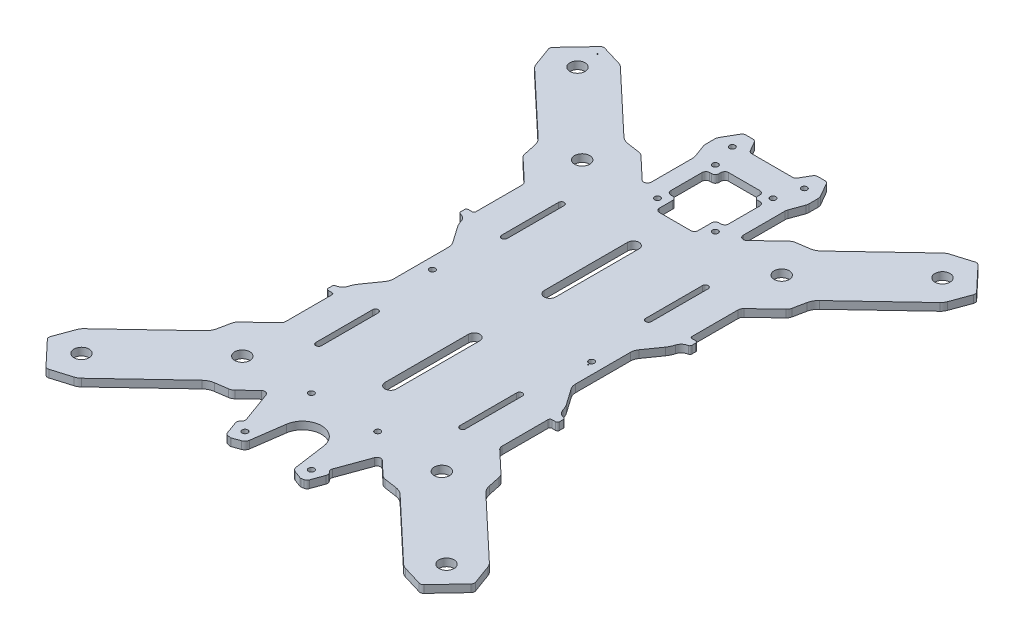
from build123d import *

# Parameters (mm, degrees)
SKETCH1_R          = 1.5
SKETCH1_R_2        = 4
SKETCH1_R_3        = 0.254
BOTTOM_PLATE_DEPTH = 4


with BuildPart() as part:
    # Sketch1 → Bottom Plate (new body)
    with BuildSketch(Plane(origin=(0, 0, 0), x_dir=(1, 0, 0), z_dir=(0, 1, 0))):
        with BuildLine():
            Line((-19.624898811, 134.691678828), (-13.018221488, 135.658834903))
            ThreePointArc((-13.018221488, 135.658834903), (-10.691575345, 136.373645712), (-8.6875614, 137.755009126))
            Line((-8.6875614, 137.755009126), (24.091416515, 168.675073503))
            ThreePointArc((24.091416515, 168.675073503), (25.204330576, 169.504226816), (26.477973526, 170.055504024))
            Line((26.477973526, 170.055504024), (36.784481999, 173.160034431))
            ThreePointArc((36.784481999, 173.160034431), (37.877411493, 173.17729229), (38.8161858, 172.617385592))
            Line((38.8161858, 172.617385592), (50.843443562, 159.867049173))
            ThreePointArc((50.843443562, 159.867049173), (51.347657912, 158.897227373), (51.266704223, 157.807166395))
            Line((51.266704223, 157.807166395), (47.566420562, 147.699238748))
            ThreePointArc((47.566420562, 147.699238748), (46.941808448, 146.459913287), (46.049166974, 145.397247256))
            Line((46.049166974, 145.397247256), (13.270189455, 114.477183253))
            ThreePointArc((13.270189455, 114.477183253), (11.774311214, 112.557136031), (10.925036406, 110.276135079))
            Line((10.925036406, 110.276135079), (9.574246944, 103.737103757))
            ThreePointArc((9.574246944, 103.737103757), (9.149610023, 102.596602447), (8.401670885, 101.636578073))
            Line((8.401670885, 101.636578073), (-2.965983987, 90.913586269))
            ThreePointArc((-2.965983987, 90.913586269), (-3.66204239, 89.919647341), (-3.907444774, 88.731291518))
            Line((-3.907444774, 88.731291518), (-3.907450446, 64.464527176))
            ThreePointArc((-3.907450446, 64.464527176), (-3.61455677, 63.757421483), (-2.907450695, 63.46452873))
            Line((-2.907450695, 63.46452873), (-0.907452036, 63.464528189))
            ThreePointArc((-0.907452036, 63.464528189), (-0.200344482, 63.171635289), (0.092549034, 62.464527992))
            Line((0.092549034, 62.464527992), (0.092549232, 60.375595433))
            ThreePointArc((0.092549232, 60.375595433), (-0.140485817, 59.733905951), (-0.730980692, 59.391288777))
            ThreePointArc((-0.730980692, 59.391288777), (-3.027155921, 58.268484481), (-4.387452049, 56.104528702))
            ThreePointArc((-4.387452049, 56.104528702), (-5.088187791, 54.273814882), (-6.077628341, 52.58161186))
            Line((-6.077628341, 52.58161186), (-11.822366716, 44.377279089))
            ThreePointArc((-11.822366716, 44.377279089), (-12.629756713, 42.740055323), (-12.907455493, 40.935820401))
            Line((-12.907455493, 40.935820401), (-12.907461824, 12.066910818))
            ThreePointArc((-12.907461824, 12.066910818), (-12.629763908, 10.262676198), (-11.822374932, 8.625452408))
            Line((-11.822374932, 8.625452408), (-6.077639868, 0.421117289))
            ThreePointArc((-6.077639868, 0.421117289), (-5.088199941, -1.271086382), (-4.387464951, -3.101800753))
            ThreePointArc((-4.387464951, -3.101800753), (-3.027169835, -5.265757168), (-0.730995131, -6.388562538))
            ThreePointArc((-0.730995131, -6.388562538), (-0.140500811, -6.731179641), (0.09253405, -7.372868644))
            Line((0.09253405, -7.372868644), (0.092534248, -9.461803425))
            ThreePointArc((0.092534248, -9.461803425), (-0.200359811, -10.16890933), (-0.907466329, -10.461801909))
            Line((-0.907466329, -10.461801909), (-2.907467998, -10.461801368))
            ThreePointArc((-2.907467998, -10.461801368), (-3.614573795, -10.754695022), (-3.9074666, -11.461801171))
            Line((-3.9074666, -11.461801171), (-3.907472272, -35.72856392))
            ThreePointArc((-3.907472272, -35.72856392), (-3.662070044, -36.916920912), (-2.966011152, -37.910860858))
            Line((-2.966011152, -37.910860858), (8.401640117, -48.633855273))
            ThreePointArc((8.401640117, -48.633855273), (9.149578237, -49.593879047), (9.574214838, -50.734379303))
            Line((9.574214838, -50.734379303), (10.925000641, -57.273415065))
            ThreePointArc((10.925000641, -57.273415065), (11.77427395, -59.554415248), (13.270150201, -61.474462442))
            Line((13.270150201, -61.474462442), (46.049117389, -92.394542749))
            ThreePointArc((46.049117389, -92.394542749), (46.941758557, -93.457210145), (47.566369902, -94.696536946))
            Line((47.566369902, -94.696536946), (51.266643639, -104.804462428))
            ThreePointArc((51.266643639, -104.804462428), (51.347623825, -105.8945101), (50.843444782, -106.864337511))
            Line((50.843444782, -106.864337511), (38.816186611, -119.614678522))
            ThreePointArc((38.816186611, -119.614678522), (37.877411266, -120.17458425), (36.784481384, -120.157326015))
            Line((36.784481384, -120.157326015), (26.477974293, -117.052786366))
            ThreePointArc((26.477974293, -117.052786366), (25.204332663, -116.501509573), (24.091419614, -115.672357204))
            Line((24.091419614, -115.672357204), (-8.687555748, -84.752285906))
            ThreePointArc((-8.687555748, -84.752285906), (-10.691567982, -83.370923772), (-13.018211962, -82.656113188))
            Line((-13.018211962, -82.656113188), (-19.624889184, -81.688950571))
            ThreePointArc((-19.624889184, -81.688950571), (-20.788211576, -81.331545356), (-21.790217948, -80.64086402))
            Line((-21.790217948, -80.64086402), (-29.02547143, -73.815918837))
            ThreePointArc((-29.02547143, -73.815918837), (-30.859146405, -73.324714244), (-32.277217146, -74.586744845))
            Line((-32.277217146, -74.586744845), (-38.206367832, -90.876949429))
            ThreePointArc((-38.206367832, -90.876949429), (-38.296598501, -91.908286737), (-37.85907169, -92.846566282))
            Line((-37.85907169, -92.846566282), (-37.302400952, -93.509977318))
            ThreePointArc((-37.302400952, -93.509977318), (-36.86487298, -94.448257233), (-36.955103118, -95.479595416))
            Line((-36.955103118, -95.479595416), (-39.324687874, -101.989981964))
            ThreePointArc((-39.324687874, -101.989981964), (-39.91849839, -102.838028097), (-40.856775935, -103.275553433))
            Line((-40.856775935, -103.275553433), (-42.176167362, -103.50820302))
            ThreePointArc((-42.176167362, -103.50820302), (-42.436971902, -103.519589968), (-42.691836905, -103.463087749))
            Line((-42.691836905, -103.463087749), (-46.669870003, -102.015201079))
            ThreePointArc((-46.669870003, -102.015201079), (-47.975246723, -101.084084501), (-48.614612679, -99.613643194))
            Line((-48.614612679, -99.613643194), (-51.004754984, -82.606900037))
            ThreePointArc((-51.004754984, -82.606900037), (-60.907435402, -73.998631063), (-70.810115964, -82.606899872))
            Line((-70.810115964, -82.606899872), (-73.200258099, -99.61364007))
            ThreePointArc((-73.200258099, -99.61364007), (-73.839623803, -101.084083654), (-75.145002094, -102.015201453))
            Line((-75.145002094, -102.015201453), (-79.123034259, -103.463086484))
            ThreePointArc((-79.123034259, -103.463086484), (-79.377898893, -103.519588734), (-79.63870308, -103.508201816))
            Line((-79.63870308, -103.508201816), (-80.958095517, -103.275555129))
            ThreePointArc((-80.958095517, -103.275555129), (-81.896373504, -102.838028656), (-82.490182969, -101.989980713))
            Line((-82.490182969, -101.989980713), (-84.85976779, -95.479601429))
            ThreePointArc((-84.85976779, -95.479601429), (-84.949998975, -94.448263707), (-84.512472115, -93.509983678))
            Line((-84.512472115, -93.509983678), (-83.955802324, -92.846566168))
            ThreePointArc((-83.955802324, -92.846566168), (-83.518277305, -91.90828859), (-83.608507711, -90.87695381))
            Line((-83.608507711, -90.87695381), (-89.537658586, -74.586749882))
            ThreePointArc((-89.537658586, -74.586749882), (-90.955728185, -73.324719412), (-92.789402057, -73.815924488))
            Line((-92.789402057, -73.815924488), (-100.024658295, -80.640868929))
            ThreePointArc((-100.024658295, -80.640868929), (-101.026663922, -81.331549011), (-102.189985044, -81.68895385))
            Line((-102.189985044, -81.68895385), (-108.796662331, -82.656110165))
            ThreePointArc((-108.796662331, -82.656110165), (-111.123308449, -83.370921057), (-113.127322343, -84.752284544))
            Line((-113.127322343, -84.752284544), (-145.906299139, -115.672350107))
            ThreePointArc((-145.906299139, -115.672350107), (-147.01921317, -116.50150346), (-148.2928561, -117.052780714))
            Line((-148.2928561, -117.052780714), (-158.599364461, -120.157311495))
            ThreePointArc((-158.599364461, -120.157311495), (-159.692293954, -120.174569393), (-160.631068282, -119.614662729))
            Line((-160.631068282, -119.614662729), (-172.658326505, -106.864326746))
            ThreePointArc((-172.658326505, -106.864326746), (-173.162535285, -105.894498992), (-173.081572191, -104.804435993))
            Line((-173.081572191, -104.804435993), (-169.381290893, -94.696507481))
            ThreePointArc((-169.381290893, -94.696507481), (-168.756679068, -93.457181874), (-167.864037843, -92.394515635))
            Line((-167.864037843, -92.394515635), (-135.08506755, -61.47444397))
            ThreePointArc((-135.08506755, -61.47444397), (-133.589189758, -59.554396399), (-132.739915484, -57.273395248))
            Line((-132.739915484, -57.273395248), (-131.38912755, -50.73436361))
            ThreePointArc((-131.38912755, -50.73436361), (-130.964490895, -49.593862201), (-130.216551982, -48.633837652))
            Line((-130.216551982, -48.633837652), (-118.848899616, -37.910843191))
            ThreePointArc((-118.848899616, -37.910843191), (-118.152841446, -36.9169041), (-117.907439339, -35.72854822))
            Line((-117.907439339, -35.72854822), (-117.907439339, -11.461783878))
            ThreePointArc((-117.907439339, -11.461783878), (-118.20033318, -10.754678254), (-118.907439324, -10.461785666))
            Line((-118.907439324, -10.461785666), (-120.907437983, -10.461785666))
            ThreePointArc((-120.907437983, -10.461785666), (-121.614545605, -10.168892932), (-121.907439287, -9.461785703))
            Line((-121.907439287, -9.461785703), (-121.907439973, -7.372853144))
            ThreePointArc((-121.907439973, -7.372853144), (-121.674405073, -6.731163608), (-121.083910279, -6.388546296))
            ThreePointArc((-121.083910279, -6.388546296), (-118.787735312, -5.265741463), (-117.42743969, -3.101785366))
            ThreePointArc((-117.42743969, -3.101785366), (-116.726704376, -1.271071382), (-115.737264222, 0.421131871))
            Line((-115.737264222, 0.421131871), (-109.992527765, 8.625465984))
            ThreePointArc((-109.992527765, 8.625465984), (-109.185138149, 10.262689939), (-108.907439791, 12.066924927))
            Line((-108.907439791, 12.066924927), (-108.907440208, 40.935834509))
            ThreePointArc((-108.907440208, 40.935834509), (-109.185138546, 42.740069064), (-109.992527905, 44.377292665))
            Line((-109.992527905, 44.377292665), (-115.737264886, 52.581626442))
            ThreePointArc((-115.737264886, 52.581626442), (-116.726705208, 54.273829882), (-117.427440626, 56.104544089))
            ThreePointArc((-117.427440626, 56.104544089), (-118.787736248, 58.268500186), (-121.083911214, 59.391305019))
            ThreePointArc((-121.083911214, 59.391305019), (-121.674405615, 59.733921985), (-121.907440626, 60.375610933))
            Line((-121.907440626, 60.375610933), (-121.907441311, 62.464545714))
            ThreePointArc((-121.907441311, 62.464545714), (-121.614547418, 63.171651687), (-120.907440969, 63.464544432))
            Line((-120.907440969, 63.464544432), (-118.9074393, 63.464544432))
            ThreePointArc((-118.9074393, 63.464544432), (-118.200333571, 63.757438252), (-117.907440932, 64.464544469))
            Line((-117.907440932, 64.464544469), (-117.907440932, 88.731307217))
            ThreePointArc((-117.907440932, 88.731307217), (-118.152843437, 89.919664153), (-118.848902561, 90.913603935))
            Line((-118.848902561, 90.913603935), (-130.216556337, 101.636595694))
            ThreePointArc((-130.216556337, 101.636595694), (-130.964494681, 102.596619293), (-131.389131549, 103.73711945))
            Line((-131.389131549, 103.73711945), (-132.739918879, 110.276154897))
            ThreePointArc((-132.739918879, 110.276154897), (-133.589192722, 112.55715488), (-135.085069422, 114.477201725))
            Line((-135.085069422, 114.477201725), (-167.864043837, 145.39727437))
            ThreePointArc((-167.864043837, 145.39727437), (-168.756685253, 146.459941558), (-169.381296888, 147.699268213))
            Line((-169.381296888, 147.699268213), (-173.081572988, 157.80719283))
            ThreePointArc((-173.081572988, 157.80719283), (-173.162537139, 158.897256863), (-172.658328228, 159.867085798))
            Line((-172.658328228, 159.867085798), (-160.631070058, 172.617426808))
            ThreePointArc((-160.631070058, 172.617426808), (-159.692294712, 173.177332536), (-158.59936483, 173.160074301))
            Line((-158.59936483, 173.160074301), (-148.292857739, 170.055534652))
            ThreePointArc((-148.292857739, 170.055534652), (-147.019215155, 169.504259148), (-145.906300934, 168.675107745))
            Line((-145.906300934, 168.675107745), (-113.127326691, 137.755035261))
            ThreePointArc((-113.127326691, 137.755035261), (-111.123314507, 136.373673054), (-108.796670552, 135.658862386))
            Line((-108.796670552, 135.658862386), (-102.189993366, 134.69169953))
            ThreePointArc((-102.189993366, 134.69169953), (-101.026670986, 134.334294273), (-100.02466464, 133.6436129))
            Line((-100.02466464, 133.6436129), (-88.529804726, 122.80062879))
            ThreePointArc((-88.529804726, 122.80062879), (-86.365207928, 122.419094725), (-85.157445861, 124.255492919))
            Line((-85.157445861, 124.255492919), (-85.157445861, 146.223235098))
            ThreePointArc((-85.157445861, 146.223235098), (-85.218214717, 146.917828337), (-85.398675306, 147.591316717))
            Line((-85.398675306, 147.591316717), (-87.916215573, 154.508206194))
            ThreePointArc((-87.916215573, 154.508206194), (-88.096675506, 155.181693006), (-88.157444275, 155.876284562))
            Line((-88.157444275, 155.876284562), (-88.157443447, 160.637471248))
            ThreePointArc((-88.157443447, 160.637471248), (-88.021145798, 161.672743632), (-87.621545033, 162.637463896))
            Line((-87.621545033, 162.637463896), (-83.53864133, 169.709253148))
            ThreePointArc((-83.53864133, 169.709253148), (-82.806590681, 170.441307337), (-81.80658869, 170.7092579))
            Line((-81.80658869, 170.7092579), (-78.008295497, 170.70925242))
            ThreePointArc((-78.008295497, 170.70925242), (-77.008296341, 170.44130377), (-76.276246154, 169.709253693))
            Line((-76.276246154, 169.709253693), (-73.389494988, 164.709250987))
            ThreePointArc((-73.389494988, 164.709250987), (-72.65744412, 163.977201303), (-71.657444781, 163.709252551))
            Line((-71.657444781, 163.709252551), (-50.157444416, 163.709247145))
            ThreePointArc((-50.157444416, 163.709247145), (-49.157443456, 163.977196702), (-48.425391933, 164.709248239))
            Line((-48.425391933, 164.709248239), (-45.538640087, 169.709240765))
            ThreePointArc((-45.538640087, 169.709240765), (-44.806589561, 170.441294654), (-43.806587847, 170.709245101))
            Line((-43.806587847, 170.709245101), (-40.008294013, 170.70923962))
            ThreePointArc((-40.008294013, 170.70923962), (-39.00829522, 170.44129081), (-38.276245312, 169.709240893))
            Line((-38.276245312, 169.709240893), (-34.19334198, 162.637440296))
            ThreePointArc((-34.19334198, 162.637440296), (-33.793741572, 161.672717889), (-33.657445349, 160.637443457))
            Line((-33.657445349, 160.637443457), (-33.657446177, 155.876261403))
            ThreePointArc((-33.657446177, 155.876261403), (-33.718215406, 155.181670039), (-33.898675724, 154.508183487))
            Line((-33.898675724, 154.508183487), (-36.416216431, 147.591297948))
            ThreePointArc((-36.416216431, 147.591297948), (-36.596677347, 146.917809458), (-36.657446483, 146.223216052))
            Line((-36.657446483, 146.223216052), (-36.657446483, 124.255476026))
            ThreePointArc((-36.657446483, 124.255476026), (-35.449686312, 122.419075302), (-33.285088228, 122.800608247))
            Line((-33.285088228, 122.800608247), (-21.790227567, 133.643592019))
            ThreePointArc((-21.790227567, 133.643592019), (-20.788221183, 134.334273409), (-19.624898811, 134.691678828))
        make_face()
        with Locations((-45.657442011, 118.501379041)):
            Circle(SKETCH1_R, mode=Mode.SUBTRACT)
        with Locations((-76.157442011, 149.001379041)):
            Circle(SKETCH1_R, mode=Mode.SUBTRACT)
        with Locations((-43.407442011, -61.853671317)):
            Circle(SKETCH1_R, mode=Mode.SUBTRACT)
        with Locations((-78.407442011, -96.853671317)):
            Circle(SKETCH1_R, mode=Mode.SUBTRACT)
        with Locations((-113.542141629, 116.151153146)):
            Circle(SKETCH1_R_2, mode=Mode.SUBTRACT)
        with Locations((-157.188079797, 157.321920462)):
            Circle(SKETCH1_R_2, mode=Mode.SUBTRACT)
        with Locations((-113.542141629, -63.148395064)):
            Circle(SKETCH1_R_2, mode=Mode.SUBTRACT)
        with Locations((-157.188079797, -104.31916238)):
            Circle(SKETCH1_R_2, mode=Mode.SUBTRACT)
        with Locations((35.373195775, -104.31916238)):
            Circle(SKETCH1_R_2, mode=Mode.SUBTRACT)
        with Locations((-8.272742394, -63.148395064)):
            Circle(SKETCH1_R_2, mode=Mode.SUBTRACT)
        with Locations((35.373195775, 157.321920462)):
            Circle(SKETCH1_R_2, mode=Mode.SUBTRACT)
        with Locations((-8.272742394, 116.151153146)):
            Circle(SKETCH1_R_2, mode=Mode.SUBTRACT)
        with Locations((-43.407442011, -96.853671317)):
            Circle(SKETCH1_R, mode=Mode.SUBTRACT)
        with Locations((-78.407442011, -61.853671317)):
            Circle(SKETCH1_R, mode=Mode.SUBTRACT)
        with Locations((-45.657442011, 149.001379041)):
            Circle(SKETCH1_R, mode=Mode.SUBTRACT)
        with Locations((-76.157442011, 118.501379041)):
            Circle(SKETCH1_R, mode=Mode.SUBTRACT)
        with Locations((-18.907442011, 26.501379041)):
            Circle(SKETCH1_R, mode=Mode.SUBTRACT)
        with Locations((-102.907442011, 26.501379041)):
            Circle(SKETCH1_R, mode=Mode.SUBTRACT)
        with Locations((-41.907442011, 161.709264285)):
            Circle(SKETCH1_R, mode=Mode.SUBTRACT)
        with Locations((-79.907442011, 161.709264285)):
            Circle(SKETCH1_R, mode=Mode.SUBTRACT)
        with Locations((-157.915717532, 168.55201377)):
            Circle(SKETCH1_R_3, mode=Mode.SUBTRACT)
        with Locations((-18.350877066, 24.149574649)):
            Circle(SKETCH1_R_3, mode=Mode.SUBTRACT)
        with BuildLine():
            Line((-100.407443829, -37.498623999), (-100.407442011, -7.498620959))
            ThreePointArc((-100.407442011, -7.498620959), (-98.907442011, -5.998620959), (-97.407442011, -7.498620959))
            Line((-97.407442011, -7.498620959), (-97.407442011, -37.498620959))
            ThreePointArc((-97.407442011, -37.498620959), (-98.9074414, -38.998621868), (-100.407443829, -37.498623999))
        make_face(mode=Mode.SUBTRACT)
        with BuildLine():
            Line((-21.407440193, 90.501380561), (-21.407442011, 60.501379041))
            ThreePointArc((-21.407442011, 60.501379041), (-22.907442011, 59.001379041), (-24.407442011, 60.501379041))
            Line((-24.407442011, 60.501379041), (-24.407442011, 90.501379041))
            ThreePointArc((-24.407442011, 90.501379041), (-22.907441862, 92.00137995), (-21.407440193, 90.501380561))
        make_face(mode=Mode.SUBTRACT)
        with BuildLine():
            Line((-73.157441691, 123.501381902), (-74.157442011, 123.501379041))
            ThreePointArc((-74.157442011, 123.501379041), (-75.571655574, 124.087165479), (-76.157442011, 125.501379041))
            Line((-76.157442011, 125.501379041), (-76.157442011, 142.001379041))
            ThreePointArc((-76.157442011, 142.001379041), (-75.571655562, 143.415592553), (-74.157442004, 144.001378892))
            Line((-74.157442004, 144.001378892), (-73.15744216, 144.00137919))
            ThreePointArc((-73.15744216, 144.00137919), (-71.743230005, 144.58716428), (-71.157442302, 146.001375353))
            Line((-71.157442302, 146.001375353), (-71.157442019, 147.001379048))
            ThreePointArc((-71.157442019, 147.001379048), (-70.571655216, 148.41559347), (-69.157440782, 149.00138024))
            Line((-69.157440782, 149.00138024), (-52.657440827, 149.001377856))
            ThreePointArc((-52.657440827, 149.001377856), (-51.243226574, 148.415590787), (-50.657440685, 147.001376046))
            Line((-50.657440685, 147.001376046), (-50.657440968, 146.001377715))
            ThreePointArc((-50.657440968, 146.001377715), (-50.0716546, 144.58716416), (-48.65744114, 144.001377566))
            Line((-48.65744114, 144.001377566), (-47.657440819, 144.001377864))
            ThreePointArc((-47.657440819, 144.001377864), (-46.243231826, 143.415593464), (-45.6574433, 142.001386179))
            Line((-45.6574433, 142.001386179), (-45.657443472, 125.501383079))
            ThreePointArc((-45.657443472, 125.501383079), (-46.243229546, 124.087170473), (-47.657442198, 123.50138451))
            Line((-47.657442198, 123.50138451), (-48.657442041, 123.501381649))
            ThreePointArc((-48.657442041, 123.501381649), (-50.071655925, 122.915594831), (-50.6574419, 121.501380598))
            Line((-50.6574419, 121.501380598), (-50.657442183, 114.50138179))
            ThreePointArc((-50.657442183, 114.50138179), (-51.243228208, 113.087169245), (-52.657440767, 112.50138325))
            Line((-52.657440767, 112.50138325), (-69.157440722, 112.50138033))
            ThreePointArc((-69.157440722, 112.50138033), (-70.571654216, 113.08716664), (-71.157440864, 114.501379995))
            Line((-71.157440864, 114.501379995), (-71.157440581, 121.501380471))
            ThreePointArc((-71.157440581, 121.501380471), (-71.743227324, 122.915594932), (-73.157441691, 123.501381902))
        make_face(mode=Mode.SUBTRACT)
        with BuildLine():
            Line((-57.907442011, 90.501382081), (-57.907442011, 46.501379041))
            ThreePointArc((-57.907442011, 46.501379041), (-60.907442011, 43.501379041), (-63.907442011, 46.501379041))
            Line((-63.907442011, 46.501379041), (-63.907442011, 90.501379041))
            ThreePointArc((-63.907442011, 90.501379041), (-60.907443531, 93.501379041), (-57.907442011, 90.501382081))
        make_face(mode=Mode.SUBTRACT)
        with BuildLine():
            Line((-63.907442037, -37.498623999), (-63.907442037, 6.501379041))
            ThreePointArc((-63.907442037, 6.501379041), (-60.907442024, 9.501379054), (-57.907442011, 6.501379041))
            Line((-57.907442011, 6.501379041), (-57.907442011, -37.498620959))
            ThreePointArc((-57.907442011, -37.498620959), (-60.907440505, -40.498620972), (-63.907442037, -37.498623999))
        make_face(mode=Mode.SUBTRACT)
        with BuildLine():
            Line((-97.407441475, 90.501382081), (-97.407442011, 60.501379041))
            ThreePointArc((-97.407442011, 60.501379041), (-98.907442011, 59.001379041), (-100.407442011, 60.501379041))
            Line((-100.407442011, 60.501379041), (-100.407442011, 90.501379041))
            ThreePointArc((-100.407442011, 90.501379041), (-98.907443263, 92.001380829), (-97.407441475, 90.501382081))
        make_face(mode=Mode.SUBTRACT)
        with BuildLine():
            Line((-24.407442548, -37.498623999), (-24.407442011, -7.498620959))
            ThreePointArc((-24.407442011, -7.498620959), (-22.907442011, -5.998620959), (-21.407442011, -7.498620959))
            Line((-21.407442011, -7.498620959), (-21.407442011, -37.498620959))
            ThreePointArc((-21.407442011, -37.498620959), (-22.90744076, -38.998621227), (-24.407442548, -37.498623999))
        make_face(mode=Mode.SUBTRACT)
    extrude(amount=BOTTOM_PLATE_DEPTH)


solid = part.part
